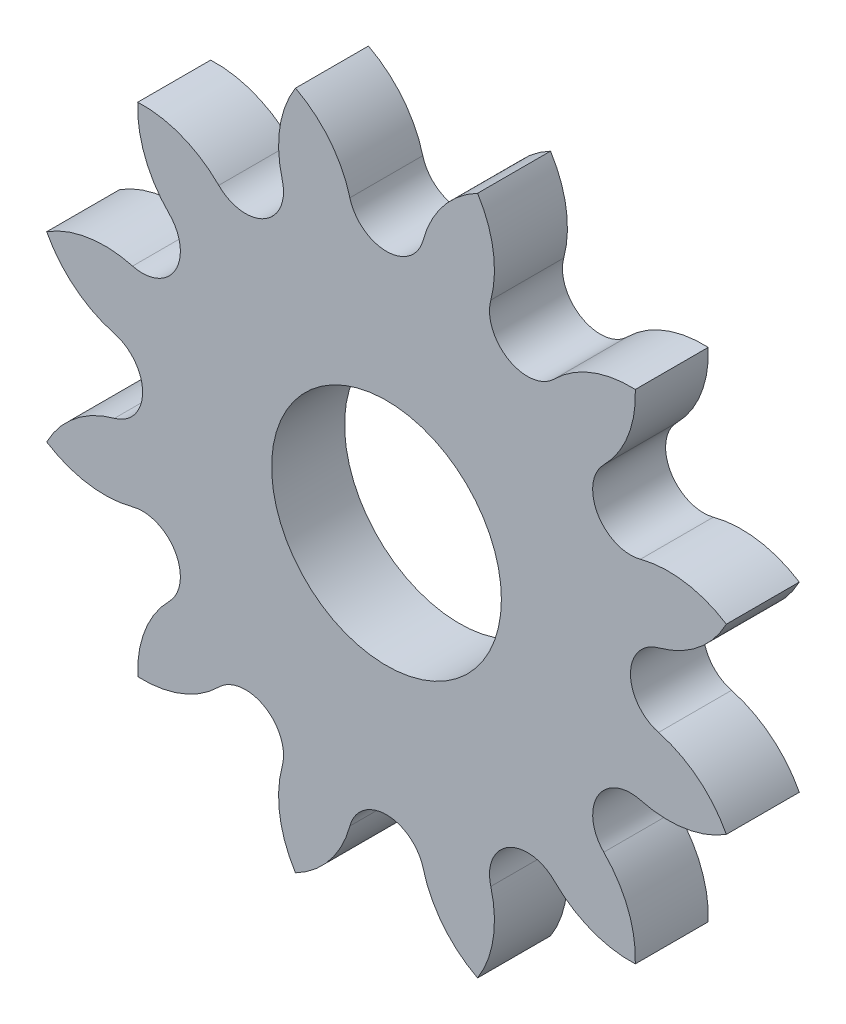
from build123d import *

# Parameters (mm, degrees)
SKETCH2_R           = 5
BOSS_EXTRUDE2_DEPTH = 3.175


with BuildPart() as part:
    # Sketch2 → Boss-Extrude2 (new body)
    with BuildSketch(Plane.XY):
        with BuildLine():
            ThreePointArc((9.456794765, 7.302125235), (10.51328966, 8.920913041), (10.82870315, 10.828049574))
            ThreePointArc((10.82870315, 10.828049574), (8.921045244, 10.513465667), (7.301533296, 9.457386704))
            ThreePointArc((7.301533296, 9.457386704), (5.308889045, 9.194845217), (4.539183834, 11.051485471))
            ThreePointArc((4.539183834, 11.051485471), (4.64471403, 12.981928422), (3.964051405, 14.791471183))
            ThreePointArc((3.964051405, 14.791471183), (2.469674584, 13.565372247), (1.59532555, 11.841424903))
            ThreePointArc((1.59532555, 11.841424903), (0.000409384, 10.617090374), (-1.594506782, 11.841424903))
            ThreePointArc((-1.594506782, 11.841424903), (-2.468043552, 13.565085875), (-3.961395494, 14.791451895))
            ThreePointArc((-3.961395494, 14.791451895), (-4.64300424, 12.982116437), (-4.538365066, 11.051485471))
            ThreePointArc((-4.538365066, 11.051485471), (-5.308070277, 9.194845217), (-7.300714528, 9.457386704))
            ThreePointArc((-7.300714528, 9.457386704), (-8.919846484, 10.513683908), (-10.827230806, 10.82870315))
            ThreePointArc((-10.827230806, 10.82870315), (-10.512252617, 8.921293027), (-9.455975997, 7.302125235))
            ThreePointArc((-9.455975997, 7.302125235), (-9.19343451, 5.309480984), (-11.050074764, 4.539775774))
            ThreePointArc((-11.050074764, 4.539775774), (-12.980517715, 4.64530597), (-14.790060475, 3.964643344))
            ThreePointArc((-14.790060475, 3.964643344), (-13.56396154, 2.470266524), (-11.840014195, 1.595917489))
            ThreePointArc((-11.840014195, 1.595917489), (-10.615679667, 0.001001323), (-11.840014195, -1.593914842))
            ThreePointArc((-11.840014195, -1.593914842), (-13.563675168, -2.467451613), (-14.790041187, -3.960803554))
            ThreePointArc((-14.790041187, -3.960803554), (-12.980705729, -4.6424123), (-11.050074764, -4.537773127))
            ThreePointArc((-11.050074764, -4.537773127), (-9.19343451, -5.307478337), (-9.455975997, -7.300122588))
            ThreePointArc((-9.455975997, -7.300122588), (-10.512273201, -8.919254544), (-10.827292443, -10.826638866))
            ThreePointArc((-10.827292443, -10.826638866), (-8.91988232, -10.511660678), (-7.300714528, -9.455384057))
            ThreePointArc((-7.300714528, -9.455384057), (-5.308070277, -9.19284257), (-4.538365066, -11.049482824))
            ThreePointArc((-4.538365066, -11.049482824), (-4.643895262, -12.979925775), (-3.963232637, -14.789468536))
            ThreePointArc((-3.963232637, -14.789468536), (-2.468855816, -13.5633696), (-1.594506782, -11.839422256))
            ThreePointArc((-1.594506782, -11.839422256), (0.000409384, -10.615087727), (1.59532555, -11.839422256))
            ThreePointArc((1.59532555, -11.839422256), (2.46886232, -13.563083228), (3.962214262, -14.789449248))
            ThreePointArc((3.962214262, -14.789449248), (4.643823008, -12.98011379), (4.539183834, -11.049482824))
            ThreePointArc((4.539183834, -11.049482824), (5.308889045, -9.19284257), (7.301533296, -9.455384057))
            ThreePointArc((7.301533296, -9.455384057), (8.920665252, -10.511681261), (10.828049574, -10.826700503))
            ThreePointArc((10.828049574, -10.826700503), (10.513071385, -8.91929038), (9.456794765, -7.300122588))
            ThreePointArc((9.456794765, -7.300122588), (9.194253278, -5.307478337), (11.050893532, -4.537773127))
            ThreePointArc((11.050893532, -4.537773127), (12.981336483, -4.643303323), (14.790879243, -3.962640697))
            ThreePointArc((14.790879243, -3.962640697), (13.564780308, -2.468263877), (11.840832964, -1.593914842))
            ThreePointArc((11.840832964, -1.593914842), (10.617899153, 0.000932392), (11.841424903, 1.59532555))
            ThreePointArc((11.841424903, 1.59532555), (13.565085875, 2.46886232), (14.791451895, 3.962214262))
            ThreePointArc((14.791451895, 3.962214262), (12.982116437, 4.643823008), (11.051485471, 4.539183834))
            ThreePointArc((11.051485471, 4.539183834), (9.193282623, 5.308357949), (9.456794765, 7.302125235))
        make_face()
        Circle(SKETCH2_R, mode=Mode.SUBTRACT)
    extrude(amount=BOSS_EXTRUDE2_DEPTH)


solid = part.part
